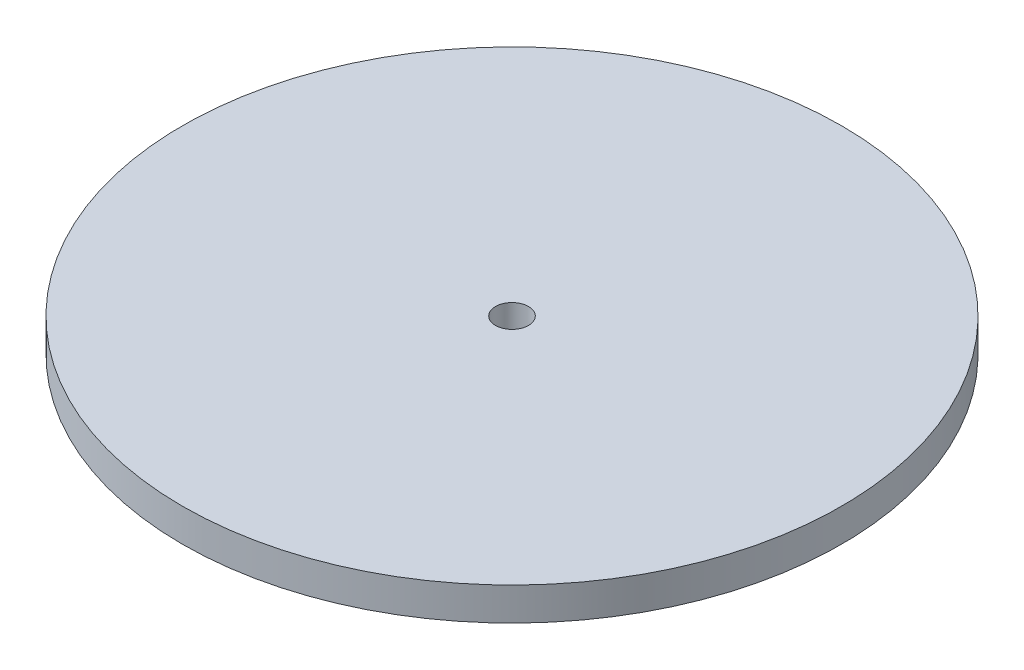
from build123d import *

# Parameters (mm, degrees)
SKETCH1_R                   = 63.5
BOSS_EXTRUDE1_DEPTH         = 6.35
F_1_4_0_25_DIAMETER_HOLE1_D = 6.35


with BuildPart() as part:
    # Sketch1 → Boss-Extrude1 (new body)
    with BuildSketch(Plane(origin=(0, 0, 0), x_dir=(1, 0, 0), z_dir=(0, 1, 0))):
        Circle(SKETCH1_R)
    extrude(amount=BOSS_EXTRUDE1_DEPTH)

    # 1/4 (0.25) Diameter Hole1 (through all)
    with Locations(Plane(origin=(0, 0, 0), x_dir=(-1, 0, 0), z_dir=(0, -1, 0))):
        with Locations((0, 0)):
            Hole(F_1_4_0_25_DIAMETER_HOLE1_D / 2)


solid = part.part
